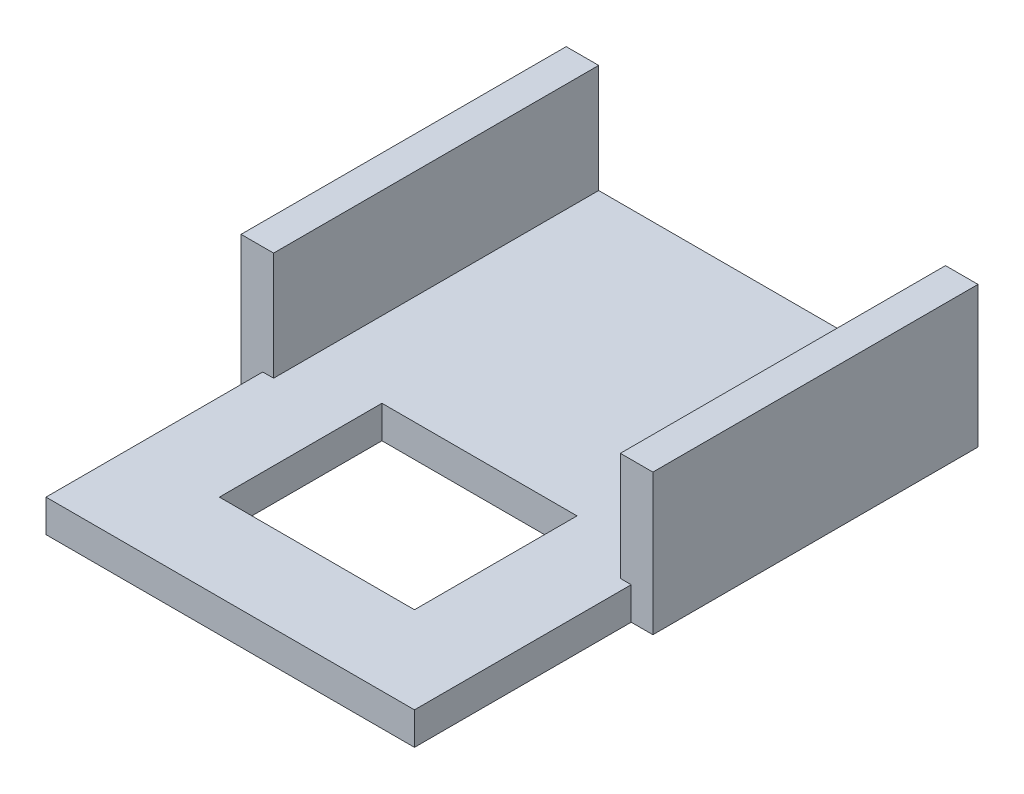
from build123d import *

# Parameters (mm, degrees)
EXTRUDE_247_DEPTH     = 3
SKETCH8_W             = 3.4
SKETCH8_H             = 0.3
EXTRUDE_374_DEPTH     = 2
SKETCH9_W             = 1.8
SKETCH9_H             = 1.5
CUT_EXTRUDE_500_DEPTH = 2


with BuildPart() as part:
    # Sketch1 → Extrude 247 (new body)
    with BuildSketch(Plane.XY):
        Polygon((-1.9, 0.65), (-1.6, 0.65), (-1.6, -0.35), (1.6, -0.35), (1.6, 0.65), (1.9, 0.65), (1.9, -0.65), (-1.9, -0.65), align=None)
    extrude(amount=EXTRUDE_247_DEPTH)

    # Sketch8 → Extrude 374 (add)
    with BuildSketch(Plane.XY.offset(3)):
        with Locations((0, -0.5)):
            Rectangle(SKETCH8_W, SKETCH8_H)
    extrude(amount=EXTRUDE_374_DEPTH)

    # Sketch9 → Cut-Extrude 500 (cut)
    with BuildSketch(Plane.XZ.offset(0.65)):
        with Locations((0, 3.45)):
            Rectangle(SKETCH9_W, SKETCH9_H)
    extrude(amount=-CUT_EXTRUDE_500_DEPTH, mode=Mode.SUBTRACT)


solid = part.part
